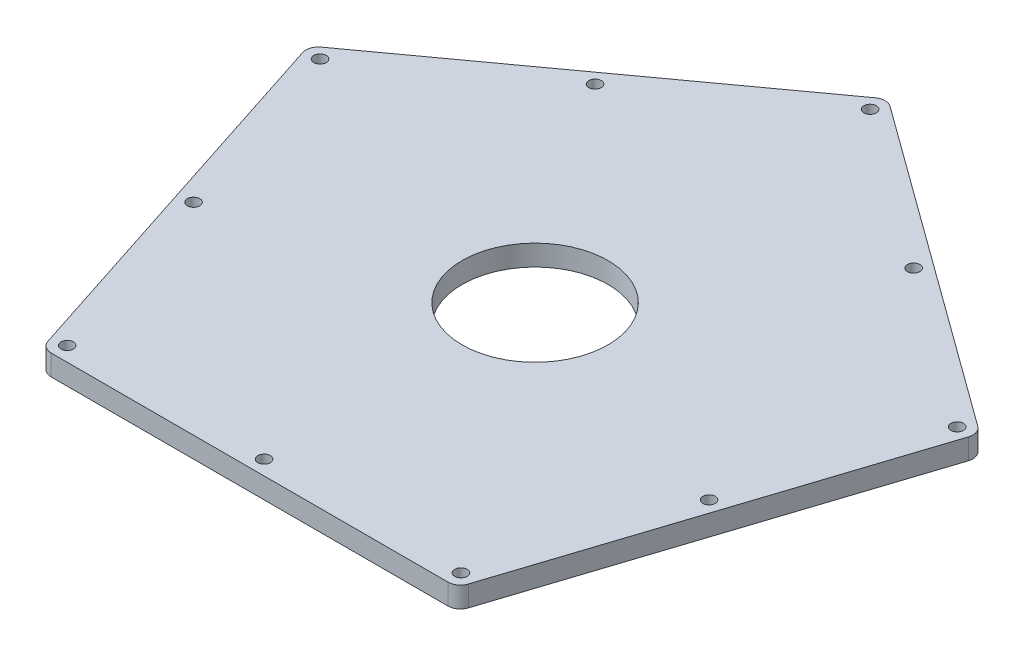
from build123d import *

# Parameters (mm, degrees)
SKETCH7_R           = 1.5
BOSS_EXTRUDE1_DEPTH = 5
SKETCH8_R           = 17.6
CUT_EXTRUDE1_DEPTH  = 5
FILLET1_R           = 3


with BuildPart() as part:
    # Sketch7 → Boss-Extrude1 (new body)
    with BuildSketch(Plane(origin=(0, -10, 0), x_dir=(1, 0, 0), z_dir=(0, 1, 0))):
        Polygon((80.901699437, 26.286555606), (0, 85.065080835), (-80.901699437, 26.286555606), (-50, -68.819096024), (50, -68.819096024), align=None)
        with Locations((62.122151912, -20.184710728)):
            Circle(SKETCH7_R, mode=Mode.SUBTRACT)
        with Locations((47.457101152, -65.319096024)):
            Circle(SKETCH7_R, mode=Mode.SUBTRACT)
        with Locations((0, -65.319096024)):
            Circle(SKETCH7_R, mode=Mode.SUBTRACT)
        with Locations((-47.457101152, -65.319096024)):
            Circle(SKETCH7_R, mode=Mode.SUBTRACT)
        with Locations((-62.122151912, -20.184710728)):
            Circle(SKETCH7_R, mode=Mode.SUBTRACT)
        with Locations((-76.787202671, 24.949674567)):
            Circle(SKETCH7_R, mode=Mode.SUBTRACT)
        with Locations((-38.393601336, 52.84425874)):
            Circle(SKETCH7_R, mode=Mode.SUBTRACT)
        with Locations((0, 80.738842914)):
            Circle(SKETCH7_R, mode=Mode.SUBTRACT)
        with Locations((76.787202671, 24.949674567)):
            Circle(SKETCH7_R, mode=Mode.SUBTRACT)
        with Locations((38.393601336, 52.84425874)):
            Circle(SKETCH7_R, mode=Mode.SUBTRACT)
    extrude(amount=BOSS_EXTRUDE1_DEPTH)

    # Sketch8 → Cut-Extrude1 (cut)
    with BuildSketch(Plane(origin=(0, -5, 0), x_dir=(1, 0, 0), z_dir=(0, 1, 0))):
        Circle(SKETCH8_R)
    extrude(amount=-CUT_EXTRUDE1_DEPTH, mode=Mode.SUBTRACT)

    # Fillet1
    fillet1_edges = [part.edges().sort_by_distance(p)[0] for p in [
        (50, -7.5, 68.819096024),
        (-50, -7.5, 68.819096024),
        (-80.901699437, -7.5, -26.286555606),
        (0, -7.5, -85.065080835),
        (80.901699437, -7.5, -26.286555606),
    ]]
    fillet(fillet1_edges, radius=FILLET1_R)


solid = part.part
